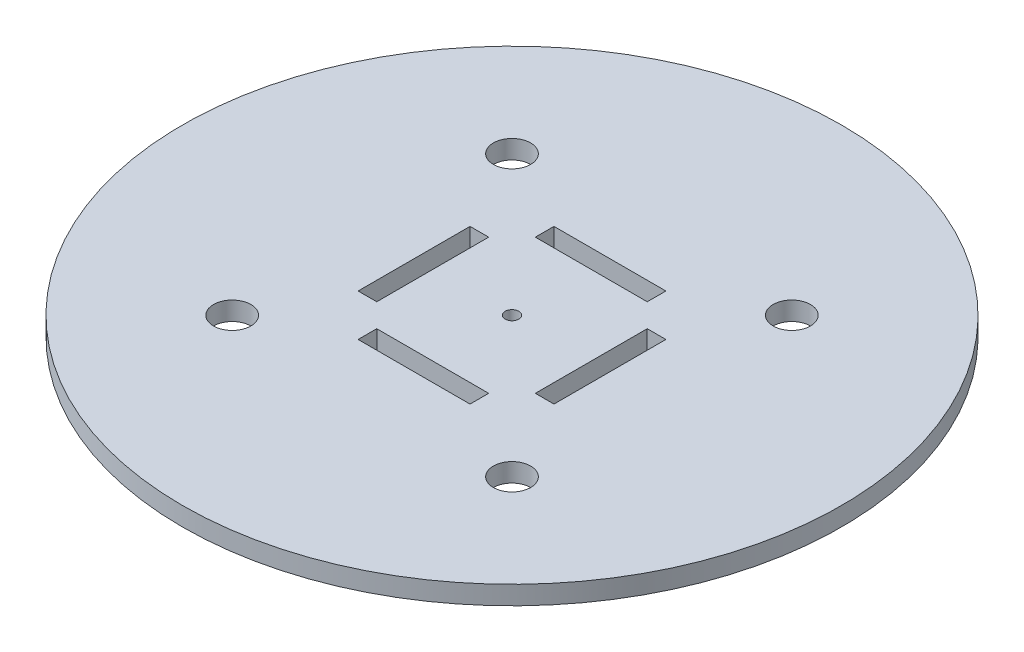
from build123d import *

# Parameters (mm, degrees)
SKETCH1_R           = 53
BOSS_EXTRUDE1_DEPTH = 3
SKETCH2_R           = 1.1
SKETCH2_W           = 18
SKETCH2_H           = 3
SKETCH2_W_2         = 3
SKETCH2_H_2         = 18
CUT_EXTRUDE1_DEPTH  = 3
SKETCH4_R           = 3
CUT_EXTRUDE2_DEPTH  = 3
CIRPATTERN1_COUNT   = 4


with BuildPart() as part:
    # Sketch1 → Boss-Extrude1 (new body)
    with BuildSketch(Plane(origin=(0, 0, 0), x_dir=(1, 0, 0), z_dir=(0, 1, 0))):
        Circle(SKETCH1_R)
    extrude(amount=BOSS_EXTRUDE1_DEPTH)

    # Sketch2 → Cut-Extrude1 (cut)
    with BuildSketch(Plane(origin=(0, 3, 0), x_dir=(1, 0, 0), z_dir=(0, 1, 0))):
        Circle(SKETCH2_R)
        with Locations((0, 14.25)):
            Rectangle(SKETCH2_W, SKETCH2_H)
        with Locations((-14.25, 0)):
            Rectangle(SKETCH2_W_2, SKETCH2_H_2)
        with Locations((0, -14.25)):
            Rectangle(SKETCH2_W, SKETCH2_H)
        with Locations((14.25, 0)):
            Rectangle(SKETCH2_W_2, SKETCH2_H_2)
    extrude(amount=-CUT_EXTRUDE1_DEPTH, mode=Mode.SUBTRACT)

    # Sketch4 → Cut-Extrude2 (cut)
    with BuildSketch(Plane(origin=(0, 3, 0), x_dir=(1, 0, 0), z_dir=(0, 1, 0))):
        with Locations((-22.5, 22.5)):
            Circle(SKETCH4_R)
    cut_extrude2 = extrude(amount=-CUT_EXTRUDE2_DEPTH, mode=Mode.SUBTRACT)

    # CirPattern1: Cut-Extrude2 ×4 about axis
    cirpattern1_axis = Axis((0, 0, 0), (0, 1, 0))
    for i in range(1, CIRPATTERN1_COUNT):
        add(cut_extrude2.rotate(cirpattern1_axis, i * 360 / CIRPATTERN1_COUNT), mode=Mode.SUBTRACT)


solid = part.part
